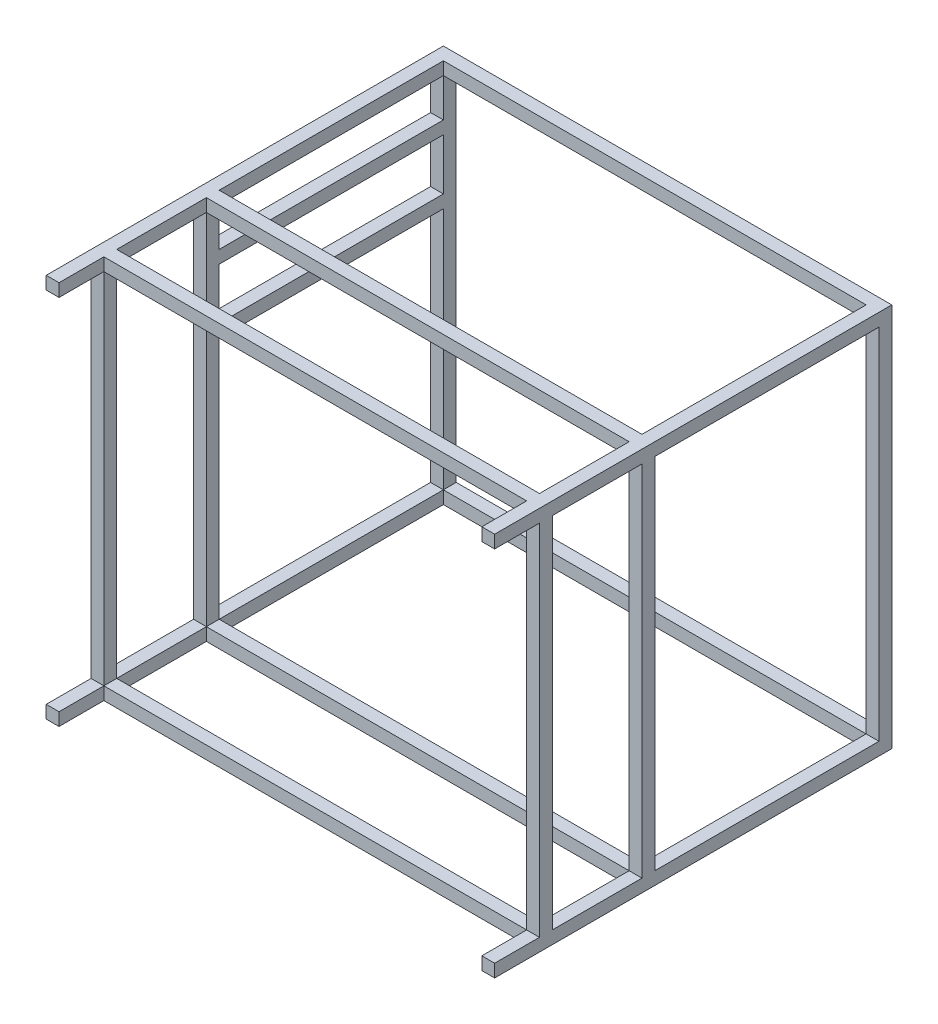
from build123d import *

# Parameters (mm, degrees)
SKETCH8_W             = 20
SKETCH8_H             = 20
BOSS_EXTRUDE5_DEPTH   = 600
BOSS_EXTRUDE5_2_DEPTH = 600
SKETCH10_W            = 900
SKETCH10_H            = 600
SKETCH10_W_2          = 860
SKETCH10_H_2          = 560
BOSS_EXTRUDE6_DEPTH   = 20
SKETCH12_W            = 900
SKETCH12_H            = 600
SKETCH12_W_2          = 860
SKETCH12_H_2          = 560
BOSS_EXTRUDE7_DEPTH   = 20
SKETCH13_W            = 20
SKETCH13_H            = 560
BOSS_EXTRUDE8_DEPTH   = 20
SKETCH14_W            = 20
SKETCH14_H            = 20
BOSS_EXTRUDE9_DEPTH   = 350
SKETCH16_W            = 900
SKETCH16_H            = 600
SKETCH16_W_2          = 860
SKETCH16_H_2          = 560
BOSS_EXTRUDE10_DEPTH  = 20
SKETCH17_W            = 200
SKETCH17_H            = 620
CUT_EXTRUDE1_DEPTH    = 601
SKETCH18_W            = 20
SKETCH18_H            = 20
BOSS_EXTRUDE11_DEPTH  = 620
SKETCH19_W            = 20
SKETCH19_H            = 20
BOSS_EXTRUDE12_DEPTH  = 560


with BuildPart() as part:
    # Sketch8 → Boss-Extrude5 (new body)
    with BuildSketch(Plane(origin=(0, 0, 4.872076023), x_dir=(-1, 0, 0), z_dir=(0, 0, -1))):
        with Locations((-1040, 690)):
            Rectangle(SKETCH8_W, SKETCH8_H)
    extrude(amount=BOSS_EXTRUDE5_DEPTH)



with BuildPart() as body_2:
    # Sketch8 → Boss-Extrude5 2 (new body)
    with BuildSketch(Plane(origin=(0, 0, 4.872076023), x_dir=(-1, 0, 0), z_dir=(0, 0, -1))):
        with Locations((-1040, 110)):
            Rectangle(SKETCH8_W, SKETCH8_H)
    extrude(amount=BOSS_EXTRUDE5_2_DEPTH)


with BuildPart() as part_1:
    add(part.part)

    add(body_2.part)  # Boss-Extrude6 merges body 2
    # Sketch10 → Boss-Extrude6 (add)
    with BuildSketch(Plane(origin=(0, 0, -595.127923977), x_dir=(-1, 0, 0), z_dir=(0, 0, -1))):
        with Locations((-600, 400)):
            Rectangle(SKETCH10_W, SKETCH10_H)
        with Locations((-600, 400)):
            Rectangle(SKETCH10_W_2, SKETCH10_H_2, mode=Mode.SUBTRACT)
    extrude(amount=BOSS_EXTRUDE6_DEPTH)

    # Sketch12 → Boss-Extrude7 (add)
    with BuildSketch(Plane.XY.offset(-245.127923977)):
        with Locations((600, 400)):
            Rectangle(SKETCH12_W, SKETCH12_H)
        with Locations((600, 400)):
            Rectangle(SKETCH12_W_2, SKETCH12_H_2, mode=Mode.SUBTRACT)
    extrude(amount=BOSS_EXTRUDE7_DEPTH)

    # Sketch13 → Boss-Extrude8 (add)
    with BuildSketch(Plane(origin=(0, 0, -615.127923977), x_dir=(-1, 0, 0), z_dir=(0, 0, -1))):
        with Locations((-360, 400)):
            Rectangle(SKETCH13_W, SKETCH13_H)
    boss_extrude8 = extrude(amount=-BOSS_EXTRUDE8_DEPTH)

    # Mirror1: Boss-Extrude8 across plane
    add(boss_extrude8.mirror(Plane(origin=(0, 0, -420.127923977), x_dir=(1, 0, 0), z_dir=(0, 0, -1))))

    # Sketch14 → Boss-Extrude9 (add)
    with BuildSketch(Plane(origin=(0, 0, -245.127923977), x_dir=(-1, 0, 0), z_dir=(0, 0, -1))):
        with Locations((-360, 610)):
            Rectangle(SKETCH14_W, SKETCH14_H)
    boss_extrude9 = extrude(amount=BOSS_EXTRUDE9_DEPTH)

    # Mirror2: Boss-Extrude9 across plane
    add(boss_extrude9.mirror(Plane(origin=(0, 560, 0), x_dir=(0, 0, 1), z_dir=(0, -1, 0))))

    # Sketch16 → Boss-Extrude10 (add)
    with BuildSketch(Plane.XY.offset(-85.127923977)):
        with Locations((600, 400)):
            Rectangle(SKETCH16_W, SKETCH16_H)
        with Locations((600, 400)):
            Rectangle(SKETCH16_W_2, SKETCH16_H_2, mode=Mode.SUBTRACT)
    extrude(amount=BOSS_EXTRUDE10_DEPTH)

    # Sketch17 → Cut-Extrude1 (cut, through all)
    with BuildSketch(Plane(origin=(0, 700, 0), x_dir=(1, 0, 0), z_dir=(0, 1, 0))):
        with Locations((250, 305.127923977)):
            Rectangle(SKETCH17_W, SKETCH17_H)
    extrude(amount=-CUT_EXTRUDE1_DEPTH, mode=Mode.SUBTRACT)

    # Sketch18 → Boss-Extrude11 (add)
    with BuildSketch(Plane(origin=(0, 0, -615.127923977), x_dir=(-1, 0, 0), z_dir=(0, 0, -1))):
        with Locations((-360, 690)):
            Rectangle(SKETCH18_W, SKETCH18_H)
        with Locations((-360, 110)):
            Rectangle(SKETCH18_W, SKETCH18_H)
    extrude(amount=-BOSS_EXTRUDE11_DEPTH)

    # Sketch19 → Boss-Extrude12 (add)
    with BuildSketch(Plane.XZ.offset(-680)):
        with Locations((360, -75.127923977)):
            Rectangle(SKETCH19_W, SKETCH19_H)
    extrude(amount=BOSS_EXTRUDE12_DEPTH)


solid = part_1.part
